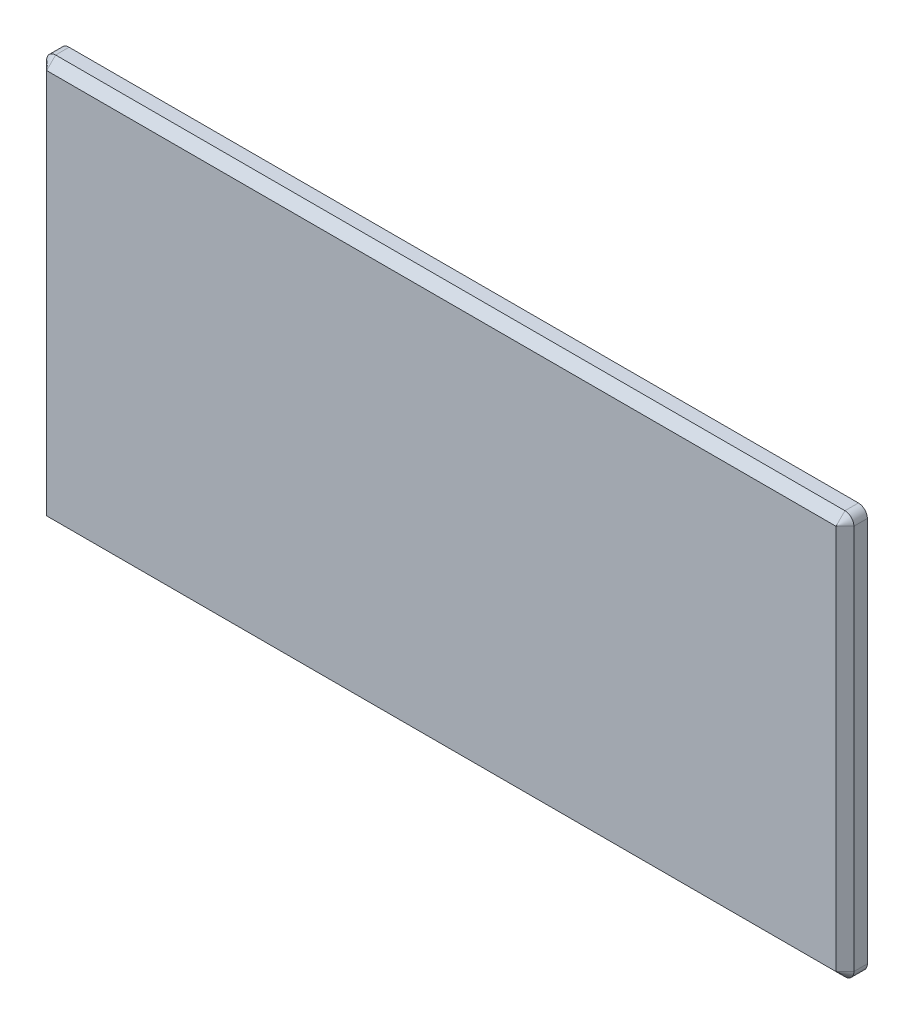
from build123d import *

# Parameters (mm, degrees)
SKETCH1_W           = 90
SKETCH1_H           = 45
BOSS_EXTRUDE1_DEPTH = 2.5
FILLET1_R           = 1
CHAMFER1_SIZE       = 1
SKETCH2_R           = 4
BOSS_EXTRUDE2_DEPTH = 10


with BuildPart() as part:
    # Sketch1 → Boss-Extrude1 (new body)
    with BuildSketch(Plane.XY):
        Rectangle(SKETCH1_W, SKETCH1_H)
    extrude(amount=BOSS_EXTRUDE1_DEPTH)

    # Fillet1
    fillet1_edges = [part.edges().sort_by_distance(p)[0] for p in [
        (45, -22.5, 1.25),
        (-45, -22.5, 1.25),
        (-45, 22.5, 1.25),
        (45, 22.5, 1.25),
    ]]
    fillet(fillet1_edges, radius=FILLET1_R)

    # Chamfer1
    chamfer1_edges = [part.edges().sort_by_distance(p)[0] for p in [
        (0, -22.5, 2.5),
        (-45, 0, 2.5),
        (45, 0, 2.5),
        (0, 22.5, 2.5),
        (44.707106781, -22.207106781, 2.5),
        (44.707106781, 22.207106781, 2.5),
        (-44.707106781, 22.207106781, 2.5),
        (-44.707106781, -22.207106781, 2.5),
    ]]
    chamfer(chamfer1_edges, length=CHAMFER1_SIZE)

    # Sketch2 → Boss-Extrude2 (add)
    with BuildSketch(Plane(origin=(0, 0, 0), x_dir=(-1, 0, 0), z_dir=(0, 0, -1))):
        with Locations((-22.5, 0)):
            Circle(SKETCH2_R)
        with Locations((22.5, 0)):
            Circle(SKETCH2_R)
    extrude(amount=BOSS_EXTRUDE2_DEPTH)


solid = part.part
